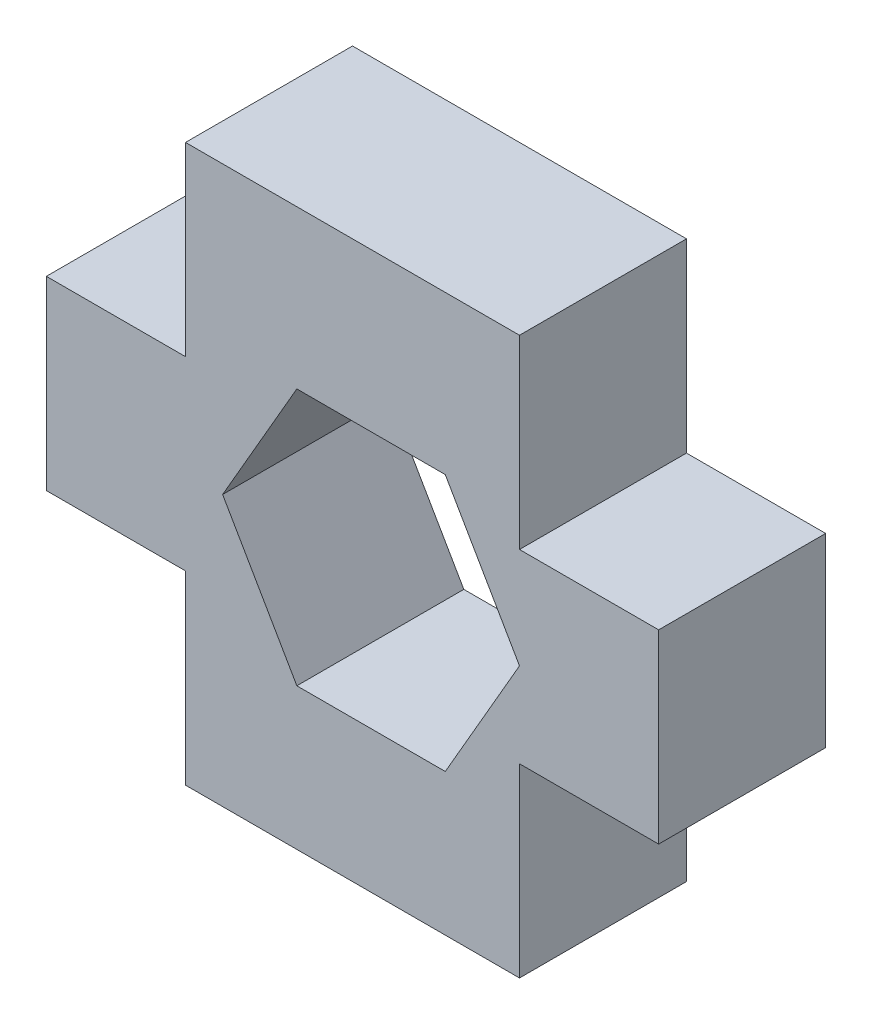
from build123d import *

# Parameters (mm, degrees)
BOSS_EXTRUDE1_DEPTH = 3.6


with BuildPart() as part:
    # Sketch1 → Boss-Extrude1 (new body)
    with BuildSketch(Plane.XY):
        Polygon((0, 0), (7.2, 0), (7.2, 4), (10.2, 4), (10.2, 8), (7.2, 8), (7.2, 12), (0, 12), (0, 8), (-3, 8), (-3, 4), (0, 4), align=None)
        Polygon((7.2, 5.826794919), (5.6, 8.598076211), (2.4, 8.598076211), (0.8, 5.826794919), (2.4, 3.055513627), (5.6, 3.055513627), align=None, mode=Mode.SUBTRACT)
    extrude(amount=BOSS_EXTRUDE1_DEPTH)


solid = part.part
